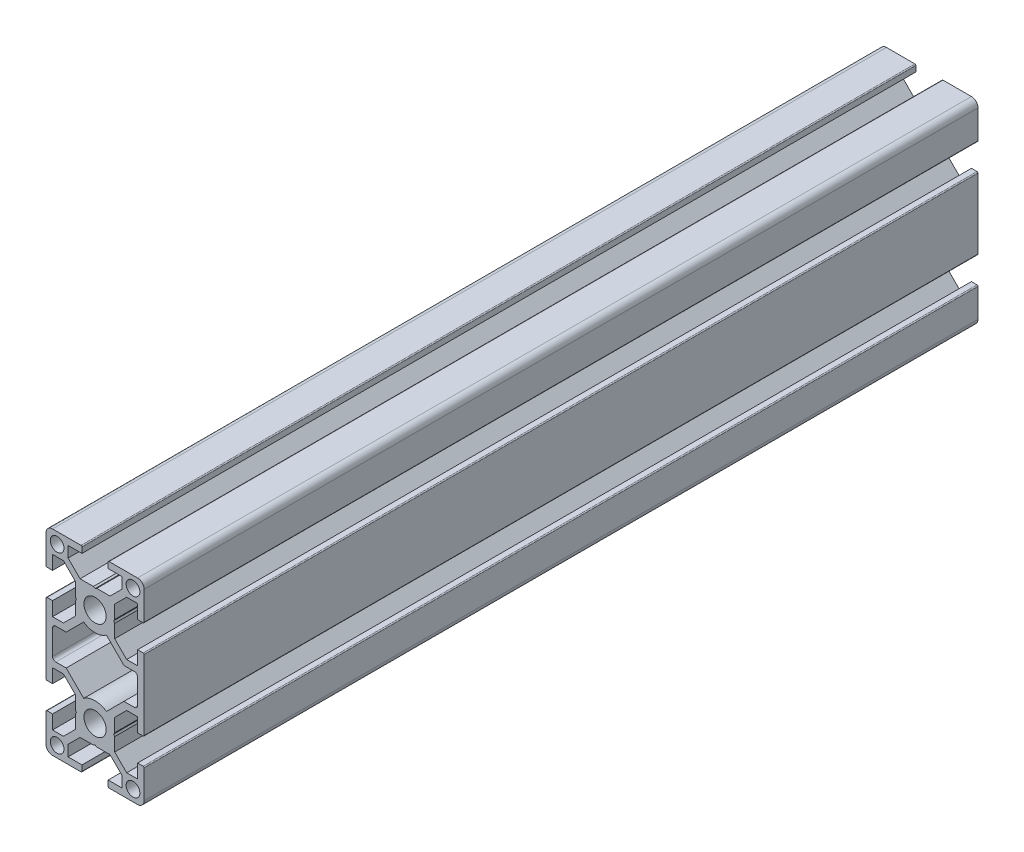
from build123d import *

# Parameters (mm, degrees)
SKETCH1_R           = 2.1
SKETCH1_R_2         = 3.4
BOSS_EXTRUDE1_DEPTH = 255


with BuildPart() as part:
    # Sketch1 → Boss-Extrude1 (new body)
    with BuildSketch(Plane(origin=(0, 0, -1000), x_dir=(-1, 0, 0), z_dir=(0, 0, -1))):
        with BuildLine():
            Line((15, -28), (15, -19.3))
            ThreePointArc((15, -19.3), (14.912132034, -19.087867966), (14.7, -19))
            Line((14.7, -19), (13, -19))
            Line((13, -19), (13, -23.25))
            Line((13, -23.25), (9.6642, -23.25))
            Line((9.6642, -23.25), (6, -19.5858))
            Line((6, -19.5858), (6, -15.519615242))
            Line((6, -15.519615242), (5.7, -15))
            Line((5.7, -15), (6, -14.480384758))
            Line((6, -14.480384758), (6, -10.4142))
            Line((6, -10.4142), (9.6642, -6.75))
            Line((9.6642, -6.75), (13, -6.75))
            Line((13, -6.75), (13, -11))
            Line((13, -11), (14.7, -11))
            ThreePointArc((14.7, -11), (14.912132034, -10.912132034), (15, -10.7))
            Line((15, -10.7), (15, 10.7))
            ThreePointArc((15, 10.7), (14.912132034, 10.912132034), (14.7, 11))
            Line((14.7, 11), (13, 11))
            Line((13, 11), (13, 6.75))
            Line((13, 6.75), (9.6642, 6.75))
            Line((9.6642, 6.75), (6, 10.4142))
            Line((6, 10.4142), (6, 14.480384758))
            Line((6, 14.480384758), (5.7, 15))
            Line((5.7, 15), (6, 15.519615242))
            Line((6, 15.519615242), (6, 19.5858))
            Line((6, 19.5858), (9.6642, 23.25))
            Line((9.6642, 23.25), (13, 23.25))
            Line((13, 23.25), (13, 19))
            Line((13, 19), (14.7, 19))
            ThreePointArc((14.7, 19), (14.912132034, 19.087867966), (15, 19.3))
            Line((15, 19.3), (15, 28))
            ThreePointArc((15, 28), (14.414213562, 29.414213562), (13, 30))
            Line((13, 30), (4.3, 30))
            ThreePointArc((4.3, 30), (4.087867966, 29.912132034), (4, 29.7))
            Line((4, 29.7), (4, 28))
            Line((4, 28), (8.25, 28))
            Line((8.25, 28), (8.25, 24.6642))
            Line((8.25, 24.6642), (4.5858, 21))
            Line((4.5858, 21), (0.519615242, 21))
            Line((0.519615242, 21), (0, 20.7))
            Line((0, 20.7), (-0.519615242, 21))
            Line((-0.519615242, 21), (-4.5858, 21))
            Line((-4.5858, 21), (-8.25, 24.6642))
            Line((-8.25, 24.6642), (-8.25, 28))
            Line((-8.25, 28), (-4, 28))
            Line((-4, 28), (-4, 29.7))
            ThreePointArc((-4, 29.7), (-4.087867966, 29.912132034), (-4.3, 30))
            Line((-4.3, 30), (-13, 30))
            ThreePointArc((-13, 30), (-14.414213562, 29.414213562), (-15, 28))
            Line((-15, 28), (-15, 19.3))
            ThreePointArc((-15, 19.3), (-14.912132034, 19.087867966), (-14.7, 19))
            Line((-14.7, 19), (-13, 19))
            Line((-13, 19), (-13, 23.25))
            Line((-13, 23.25), (-9.6642, 23.25))
            Line((-9.6642, 23.25), (-6, 19.5858))
            Line((-6, 19.5858), (-6, 15.519615242))
            Line((-6, 15.519615242), (-5.7, 15))
            Line((-5.7, 15), (-6, 14.480384758))
            Line((-6, 14.480384758), (-6, 10.4142))
            Line((-6, 10.4142), (-9.6642, 6.75))
            Line((-9.6642, 6.75), (-13, 6.75))
            Line((-13, 6.75), (-13, 11))
            Line((-13, 11), (-14.7, 11))
            ThreePointArc((-14.7, 11), (-14.912132034, 10.912132034), (-15, 10.7))
            Line((-15, 10.7), (-15, -10.7))
            ThreePointArc((-15, -10.7), (-14.912132034, -10.912132034), (-14.7, -11))
            Line((-14.7, -11), (-13, -11))
            Line((-13, -11), (-13, -6.75))
            Line((-13, -6.75), (-9.6642, -6.75))
            Line((-9.6642, -6.75), (-6, -10.4142))
            Line((-6, -10.4142), (-6, -14.480384758))
            Line((-6, -14.480384758), (-5.7, -15))
            Line((-5.7, -15), (-6, -15.519615242))
            Line((-6, -15.519615242), (-6, -19.5858))
            Line((-6, -19.5858), (-9.6642, -23.25))
            Line((-9.6642, -23.25), (-13, -23.25))
            Line((-13, -23.25), (-13, -19))
            Line((-13, -19), (-14.7, -19))
            ThreePointArc((-14.7, -19), (-14.912132034, -19.087867966), (-15, -19.3))
            Line((-15, -19.3), (-15, -28))
            ThreePointArc((-15, -28), (-14.414213562, -29.414213562), (-13, -30))
            Line((-13, -30), (-4.3, -30))
            ThreePointArc((-4.3, -30), (-4.087867966, -29.912132034), (-4, -29.7))
            Line((-4, -29.7), (-4, -28))
            Line((-4, -28), (-8.25, -28))
            Line((-8.25, -28), (-8.25, -24.6642))
            Line((-8.25, -24.6642), (-4.5858, -21))
            Line((-4.5858, -21), (-0.519615242, -21))
            Line((-0.519615242, -21), (0, -20.7))
            Line((0, -20.7), (0.519615242, -21))
            Line((0.519615242, -21), (4.5858, -21))
            Line((4.5858, -21), (8.25, -24.6642))
            Line((8.25, -24.6642), (8.25, -28))
            Line((8.25, -28), (4, -28))
            Line((4, -28), (4, -29.7))
            ThreePointArc((4, -29.7), (4.087867966, -29.912132034), (4.3, -30))
            Line((4.3, -30), (13, -30))
            ThreePointArc((13, -30), (14.414213562, -29.414213562), (15, -28))
        make_face()
        with Locations((11.6, 26.625)):
            Circle(SKETCH1_R, mode=Mode.SUBTRACT)
        with Locations((11.6, -26.625)):
            Circle(SKETCH1_R, mode=Mode.SUBTRACT)
        with Locations((0, -15)):
            Circle(SKETCH1_R_2, mode=Mode.SUBTRACT)
        with Locations((0, 15)):
            Circle(SKETCH1_R_2, mode=Mode.SUBTRACT)
        with Locations((-11.6, 26.625)):
            Circle(SKETCH1_R, mode=Mode.SUBTRACT)
        with Locations((-11.6, -26.625)):
            Circle(SKETCH1_R, mode=Mode.SUBTRACT)
        with BuildLine():
            Line((13, 3.75), (13, -3.75))
            ThreePointArc((13, -3.75), (12.707106781, -4.457106781), (12, -4.75))
            Line((12, -4.75), (8.8358, -4.75))
            Line((8.8358, -4.75), (3.476201279, -10.109598721))
            ThreePointArc((3.476201279, -10.109598721), (0, -9), (-3.476201279, -10.109598721))
            Line((-3.476201279, -10.109598721), (-8.8358, -4.75))
            Line((-8.8358, -4.75), (-12, -4.75))
            ThreePointArc((-12, -4.75), (-12.707106781, -4.457106781), (-13, -3.75))
            Line((-13, -3.75), (-13, 3.75))
            ThreePointArc((-13, 3.75), (-12.707106781, 4.457106781), (-12, 4.75))
            Line((-12, 4.75), (-8.8358, 4.75))
            Line((-8.8358, 4.75), (-3.476201279, 10.109598721))
            ThreePointArc((-3.476201279, 10.109598721), (0, 9), (3.476201279, 10.109598721))
            Line((3.476201279, 10.109598721), (8.8358, 4.75))
            Line((8.8358, 4.75), (12, 4.75))
            ThreePointArc((12, 4.75), (12.707106781, 4.457106781), (13, 3.75))
        make_face(mode=Mode.SUBTRACT)
    extrude(amount=-BOSS_EXTRUDE1_DEPTH)


solid = part.part
